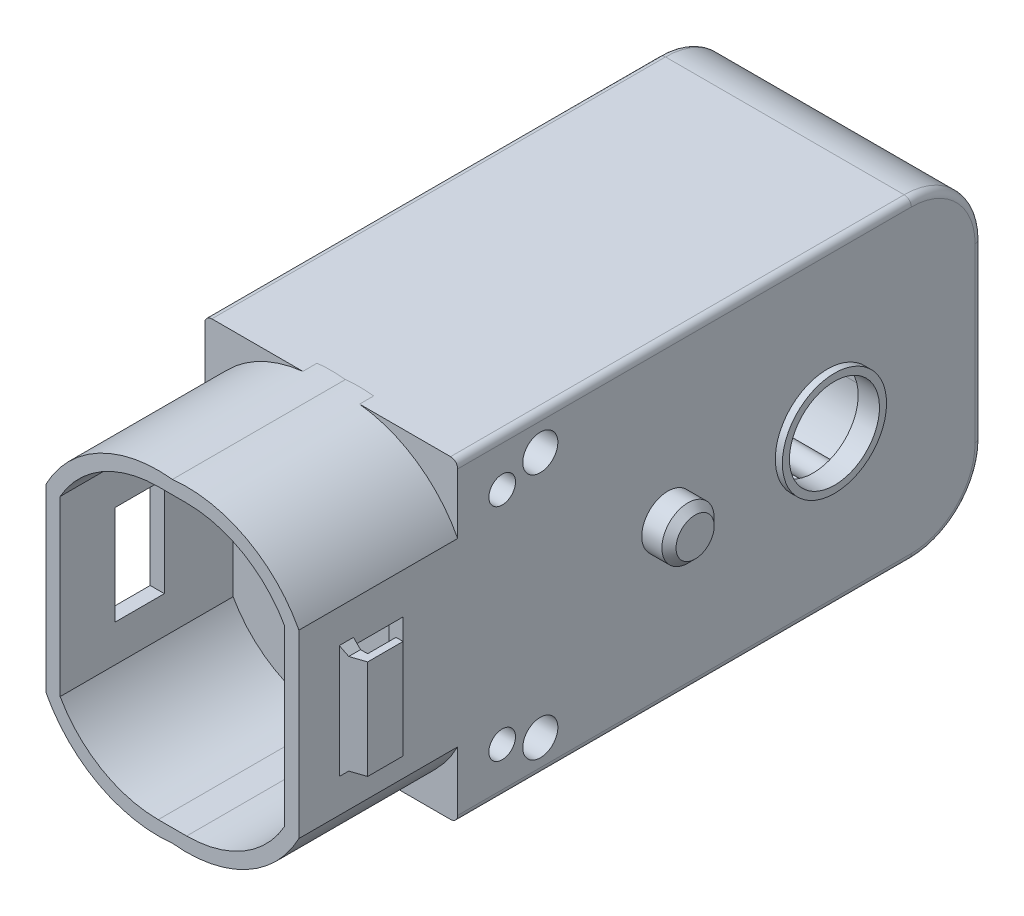
from build123d import *

# Parameters (mm, degrees)
BOSS_EXTRUDE1_DEPTH  = 11.2
BOSS_EXTRUDE2_START  = 1
BOSS_EXTRUDE2_DEPTH  = 1
BOSS_EXTRUDE4_DEPTH  = 36
SKETCH5_W            = 8.920001513
SKETCH5_H            = 22.167921158
BOSS_EXTRUDE6_DEPTH  = 2
FILLET2_R            = 5
SKETCH6_W            = 1.4
SKETCH6_H            = 5
BOSS_EXTRUDE7_DEPTH  = 4.8
SKETCH7_R            = 1.38
CUT_EXTRUDE1_DEPTH   = 4.8
SKETCH8_R            = 3.675
SKETCH8_R_2          = 3.175
BOSS_EXTRUDE8_DEPTH  = 0.5
CUT_EXTRUDE2_START   = -7.5
SKETCH9_R            = 3.175
CUT_EXTRUDE2_DEPTH   = 7.5
CHAMFER1_SIZE        = 1
SKETCH10_R           = 1.845
BOSS_EXTRUDE9_DEPTH  = 1.92
CHAMFER2_SIZE        = 0.5
SKETCH11_R           = 1.5
CUT_EXTRUDE3_DEPTH   = 1.92
SKETCH12_R           = 1.15
CUT_EXTRUDE4_DEPTH   = 1.92
BOSS_EXTRUDE13_DEPTH = 0.5
SKETCH14_W           = 3.5
SKETCH14_H           = 7
CUT_EXTRUDE6_DEPTH   = 5.5
BOSS_EXTRUDE14_DEPTH = 7
SKETCH16_W           = 0.5
SKETCH16_H           = 7
BOSS_EXTRUDE16_DEPTH = 2
CHAMFER3_SIZE        = 0.5
SKETCH20_R           = 0.5
BOSS_EXTRUDE19_DEPTH = 15
BOSS_EXTRUDE23_START = -1
SKETCH21_R           = 1.5
SKETCH21_R_2         = 1.237971005
SKETCH21_R_3         = 1.15
SKETCH21_R_4         = 0.940138742
BOSS_EXTRUDE23_DEPTH = 1
SKETCH21_2_R         = 1.5
SKETCH21_2_R_2       = 1.237971005
SKETCH21_2_R_3       = 1.15
SKETCH21_2_R_4       = 0.940138742
BOSS_EXTRUDE24_DEPTH = 8
SKETCH22_R           = 0.8
SKETCH22_R_2         = 0.5
BOSS_EXTRUDE25_DEPTH = 8
FILLET4_R            = 0.5


with BuildPart() as part:
    # Sketch1 → Boss-Extrude1 (new body)
    with BuildSketch(Plane.XY):
        with BuildLine():
            Line((0, 11.115), (0, 10.171175948))
            Line((0, 10.171175948), (-1, 10.171175948))
            ThreePointArc((-1, 10.171175948), (-5.011187662, 9.081675078), (-7.920001513, 6.112594314))
            Line((-7.920001513, 6.112594314), (-7.920001513, -6.112594314))
            ThreePointArc((-7.920001513, -6.112594314), (-5.011187662, -9.081675078), (-1, -10.171175948))
            Line((-1, -10.171175948), (0, -10.171175948))
            Line((0, -10.171175948), (0, -11.115))
            ThreePointArc((0, -11.115), (-5.196692773, -10.123430296), (-8.920001513, -6.365))
            Line((-8.920001513, -6.365), (-8.920001513, 6.365))
            ThreePointArc((-8.920001513, 6.365), (-5.196692773, 10.123430296), (0, 11.115))
        make_face()
    extrude(amount=BOSS_EXTRUDE1_DEPTH)

    # Sketch2 → Boss-Extrude2 (add)
    with BuildSketch(Plane(origin=(0, 0, 0), x_dir=(-1, 0, 0), z_dir=(0, 0, -1)).offset(BOSS_EXTRUDE2_START)):
        with BuildLine():
            Line((2, 11.115), (8.920001513, 11.115))
            Line((8.920001513, 11.115), (8.920001513, -11.052921158))
            Line((8.920001513, -11.052921158), (2.44835684, -11.052921158))
            ThreePointArc((2.44835684, -11.052921158), (1.226317056, -11.16830724), (0, -11.115))
            Line((0, -11.115), (0, -10.171175948))
            Line((0, -10.171175948), (1, -10.171175948))
            ThreePointArc((1, -10.171175948), (5.011187662, -9.081675078), (7.920001513, -6.112594314))
            Line((7.920001513, -6.112594314), (7.920001513, 6.112594314))
            ThreePointArc((7.920001513, 6.112594314), (5.011187662, 9.081675078), (1, 10.171175948))
            Line((1, 10.171175948), (0, 10.171175948))
            Line((0, 10.171175948), (0, 11.115))
            ThreePointArc((0, 11.115), (1, 11.171175948), (2, 11.115))
        make_face()
    extrude(amount=-BOSS_EXTRUDE2_DEPTH)

    # Sketch4 → Boss-Extrude4 (add)
    with BuildSketch(Plane(origin=(0, 0, -1), x_dir=(-1, 0, 0), z_dir=(0, 0, -1))):
        Polygon((8.920001513, 11.115), (0, 11.115), (0, 10.115), (1, 10.115), (7.920001513, 10.115), (7.920001513, -10.052921158), (1, -10.052921158), (0, -10.052921158), (0, -11.052921158), (8.920001513, -11.052921158), align=None)
    extrude(amount=BOSS_EXTRUDE4_DEPTH)

    # Sketch5 → Boss-Extrude6 (add)
    with BuildSketch(Plane(origin=(0, 0, -37), x_dir=(-1, 0, 0), z_dir=(0, 0, -1))):
        with Locations((4.460000757, 0.031039421)):
            Rectangle(SKETCH5_W, SKETCH5_H)
    extrude(amount=-BOSS_EXTRUDE6_DEPTH)

    # Fillet2
    fillet2_edges = [part.edges().sort_by_distance(p)[0] for p in [
        (-3.960000757, -10.052921158, -35),
        (-3.960000757, 10.115, -35),
        (-4.460000757, -11.052921158, -37),
        (-4.460000757, 11.115, -37),
    ]]
    fillet(fillet2_edges, radius=FILLET2_R)

    # Sketch6 → Boss-Extrude7 (add)
    with BuildSketch(Plane(origin=(0, 0, -37), x_dir=(-1, 0, 0), z_dir=(0, 0, -1))):
        with Locations((0.7, 0)):
            Rectangle(SKETCH6_W, SKETCH6_H)
    extrude(amount=BOSS_EXTRUDE7_DEPTH)

    # Sketch7 → Cut-Extrude1 (cut)
    with BuildSketch(Plane.ZY.offset(1.4)):
        with Locations((-39.4, 0)):
            Circle(SKETCH7_R)
    extrude(amount=-CUT_EXTRUDE1_DEPTH, mode=Mode.SUBTRACT)

    # Sketch8 → Boss-Extrude8 (add)
    with BuildSketch(Plane.ZY.offset(8.920001513)):
        with Locations((-26.08, 0)):
            Circle(SKETCH8_R)
        with Locations((-26.08, 0)):
            Circle(SKETCH8_R_2, mode=Mode.SUBTRACT)
    extrude(amount=BOSS_EXTRUDE8_DEPTH)

    # Sketch9 → Cut-Extrude2 (cut)
    with BuildSketch(Plane.ZY.offset(8.920001513).offset(CUT_EXTRUDE2_START)):
        with Locations((-26.08, 0)):
            Circle(SKETCH9_R)
    extrude(amount=CUT_EXTRUDE2_DEPTH, mode=Mode.SUBTRACT)

    # Chamfer1
    chamfer1_edges = [part.edges().sort_by_distance(p)[0] for p in [
        (-0.7, -2.5, -37),
        (-0.7, 2.5, -37),
    ]]
    chamfer(chamfer1_edges, length=CHAMFER1_SIZE)

    # Sketch10 → Boss-Extrude9 (add)
    with BuildSketch(Plane.ZY.offset(8.920001513)):
        with Locations((-14.83, 0)):
            Circle(SKETCH10_R)
    extrude(amount=BOSS_EXTRUDE9_DEPTH)

    # Chamfer2
    chamfer2_edges = [part.edges().sort_by_distance(p)[0] for p in [
        (-10.840001513, 0, -16.675),
    ]]
    chamfer(chamfer2_edges, length=CHAMFER2_SIZE)

    # Sketch11 → Cut-Extrude3 (cut)
    with BuildSketch(Plane.ZY.offset(8.920001513)):
        with Locations((-5.83, 8.71)):
            Circle(SKETCH11_R)
        with Locations((-5.83, -8.71)):
            Circle(SKETCH11_R)
    extrude(amount=-CUT_EXTRUDE3_DEPTH, mode=Mode.SUBTRACT)

    # Sketch12 → Cut-Extrude4 (cut)
    with BuildSketch(Plane.ZY.offset(8.920001513)):
        with Locations((-3.140037022, 7.781512681)):
            Circle(SKETCH12_R)
        with Locations((-3.140037022, -7.781512681)):
            Circle(SKETCH12_R)
    extrude(amount=-CUT_EXTRUDE4_DEPTH, mode=Mode.SUBTRACT)

    # Sketch13 → Boss-Extrude13 (add)
    with BuildSketch(Plane(origin=(0, 0, -1), x_dir=(-1, 0, 0), z_dir=(0, 0, -1))):
        with BuildLine():
            Line((7.920001513, 10.115), (0, 10.115))
            Line((0, 10.115), (0, 2.5))
            ThreePointArc((0, 2.5), (2.5, 0), (0, -2.5))
            Line((0, -2.5), (0, -10.115))
            Line((0, -10.115), (0, -10.171175948))
            Line((0, -10.171175948), (0.5, -10.171175948))
            Line((0.5, -10.171175948), (7.920001513, -10.171175948))
            Line((7.920001513, -10.171175948), (7.920001513, 10.115))
        make_face()
    extrude(amount=BOSS_EXTRUDE13_DEPTH)

    # Sketch14 → Cut-Extrude6 (cut)
    with BuildSketch(Plane.ZY.offset(8.920001513)):
        with Locations((5.6, 0)):
            Rectangle(SKETCH14_W, SKETCH14_H)
    extrude(amount=-CUT_EXTRUDE6_DEPTH, mode=Mode.SUBTRACT)

    # Sketch15 → Boss-Extrude14 (add)
    with BuildSketch(Plane.XZ.offset(-3.5)):
        Polygon((-8.920001513, 7.35), (-10.420001513, 7.35), (-10.420001513, 7.85), (-8.920001513, 8.35), align=None)
    extrude(amount=BOSS_EXTRUDE14_DEPTH)

    # Sketch16 → Boss-Extrude16 (add)
    with BuildSketch(Plane(origin=(0, 0, 7.35), x_dir=(-1, 0, 0), z_dir=(0, 0, -1))):
        with Locations((10.170001513, 0)):
            Rectangle(SKETCH16_W, SKETCH16_H)
    extrude(amount=BOSS_EXTRUDE16_DEPTH)

    # Chamfer3
    chamfer3_edges = [part.edges().sort_by_distance(p)[0] for p in [
        (-8.920001513, -3.5, 7.85),
        (-8.920001513, 3.5, 7.85),
    ]]
    chamfer(chamfer3_edges, length=CHAMFER3_SIZE)

    # Sketch20 → Boss-Extrude19 (add)
    with BuildSketch(Plane(origin=(-7.920001513, 0, 0), x_dir=(0, 0, -1), z_dir=(1, 0, 0))):
        with Locations((16.425, 0)):
            Circle(SKETCH20_R)
    extrude(amount=BOSS_EXTRUDE19_DEPTH)

    # Sketch21 → Boss-Extrude23 (add)
    # profile 1 of 4: a face of its own
    with BuildSketch(Plane(origin=(-7.920001513, 0, 0), x_dir=(0, 0, -1), z_dir=(1, 0, 0)).offset(BOSS_EXTRUDE23_START)):
        with Locations((5.83, 8.71)):
            Circle(SKETCH21_R)
        with Locations((5.83, 8.71)):
            Circle(SKETCH21_R_2, mode=Mode.SUBTRACT)
    # profile 2 of 4: a face of its own
    with BuildSketch(Plane(origin=(-7.920001513, 0, 0), x_dir=(0, 0, -1), z_dir=(1, 0, 0)).offset(BOSS_EXTRUDE23_START)):
        with Locations((3.140037022, 7.781512681)):
            Circle(SKETCH21_R_3)
        with Locations((3.140037022, 7.781512681)):
            Circle(SKETCH21_R_4, mode=Mode.SUBTRACT)
    # profile 3 of 4: a face of its own
    with BuildSketch(Plane(origin=(-7.920001513, 0, 0), x_dir=(0, 0, -1), z_dir=(1, 0, 0)).offset(BOSS_EXTRUDE23_START)):
        with Locations((3.140037022, -7.781512681)):
            Circle(SKETCH21_R_3)
        with Locations((3.140037022, -7.781512681)):
            Circle(SKETCH21_R_4, mode=Mode.SUBTRACT)
    # profile 4 of 4: a face of its own
    with BuildSketch(Plane(origin=(-7.920001513, 0, 0), x_dir=(0, 0, -1), z_dir=(1, 0, 0)).offset(BOSS_EXTRUDE23_START)):
        with Locations((5.83, -8.71)):
            Circle(SKETCH21_R)
        with Locations((5.83, -8.71)):
            Circle(SKETCH21_R_2, mode=Mode.SUBTRACT)
    extrude(amount=BOSS_EXTRUDE23_DEPTH)

    # Sketch21_2 → Boss-Extrude24 (add)
    # profile 1 of 4: a face of its own
    with BuildSketch(Plane(origin=(-7.920001513, 0, 0), x_dir=(0, 0, -1), z_dir=(1, 0, 0))):
        with Locations((5.83, 8.71)):
            Circle(SKETCH21_2_R)
        with Locations((5.83, 8.71)):
            Circle(SKETCH21_2_R_2, mode=Mode.SUBTRACT)
    # profile 2 of 4: a face of its own
    with BuildSketch(Plane(origin=(-7.920001513, 0, 0), x_dir=(0, 0, -1), z_dir=(1, 0, 0))):
        with Locations((3.140037022, 7.781512681)):
            Circle(SKETCH21_2_R_3)
        with Locations((3.140037022, 7.781512681)):
            Circle(SKETCH21_2_R_4, mode=Mode.SUBTRACT)
    # profile 3 of 4: a face of its own
    with BuildSketch(Plane(origin=(-7.920001513, 0, 0), x_dir=(0, 0, -1), z_dir=(1, 0, 0))):
        with Locations((3.140037022, -7.781512681)):
            Circle(SKETCH21_2_R_3)
        with Locations((3.140037022, -7.781512681)):
            Circle(SKETCH21_2_R_4, mode=Mode.SUBTRACT)
    # profile 4 of 4: a face of its own
    with BuildSketch(Plane(origin=(-7.920001513, 0, 0), x_dir=(0, 0, -1), z_dir=(1, 0, 0))):
        with Locations((5.83, -8.71)):
            Circle(SKETCH21_2_R)
        with Locations((5.83, -8.71)):
            Circle(SKETCH21_2_R_2, mode=Mode.SUBTRACT)
    extrude(amount=BOSS_EXTRUDE24_DEPTH)

    # Sketch22 → Boss-Extrude25 (add)
    # profile 1 of 4: a face of its own
    with BuildSketch(Plane(origin=(-7.920001513, 0, 0), x_dir=(0, 0, -1), z_dir=(1, 0, 0))):
        with Locations((17.526449978, 9.081390514)):
            Circle(SKETCH22_R)
        with Locations((17.526449978, 9.081390514)):
            Circle(SKETCH22_R_2, mode=Mode.SUBTRACT)
    # profile 2 of 4: a face of its own
    with BuildSketch(Plane(origin=(-7.920001513, 0, 0), x_dir=(0, 0, -1), z_dir=(1, 0, 0))):
        with Locations((31.797803684, 8.592263442)):
            Circle(SKETCH22_R)
        with Locations((31.797803684, 8.592263442)):
            Circle(SKETCH22_R_2, mode=Mode.SUBTRACT)
    # profile 3 of 4: a face of its own
    with BuildSketch(Plane(origin=(-7.920001513, 0, 0), x_dir=(0, 0, -1), z_dir=(1, 0, 0))):
        with Locations((31.797803684, -8.592263442)):
            Circle(SKETCH22_R)
        with Locations((31.797803684, -8.592263442)):
            Circle(SKETCH22_R_2, mode=Mode.SUBTRACT)
    # profile 4 of 4: a face of its own
    with BuildSketch(Plane(origin=(-7.920001513, 0, 0), x_dir=(0, 0, -1), z_dir=(1, 0, 0))):
        with Locations((17.526449978, -9.081390514)):
            Circle(SKETCH22_R)
        with Locations((17.526449978, -9.081390514)):
            Circle(SKETCH22_R_2, mode=Mode.SUBTRACT)
    extrude(amount=BOSS_EXTRUDE25_DEPTH)

    # Mirror7: part across plane


with BuildPart() as part_1:
    add(part.part)
    add(part.part.mirror(Plane(origin=(0, 0, 0), x_dir=(0, 0, 1), z_dir=(1, 0, 0))))

    # Fillet4
    fillet4_edges = [part_1.edges().sort_by_distance(p)[0] for p in [
        (-8.920001513, -11.052921158, -16),
        (-8.920001513, -9.588455064, -35.535533906),
        (-8.920001513, 0.031039421, -37),
        (-8.920001513, 9.650533906, -35.535533906),
        (8.920001513, -11.052921158, -16),
        (8.920001513, -9.588455064, -35.535533906),
        (8.920001513, 0.031039421, -37),
        (8.920001513, 9.650533906, -35.535533906),
        (-8.920001513, 11.115, -16),
        (8.920001513, 11.115, -16),
    ]]
    fillet(fillet4_edges, radius=FILLET4_R)


solid = part_1.part
